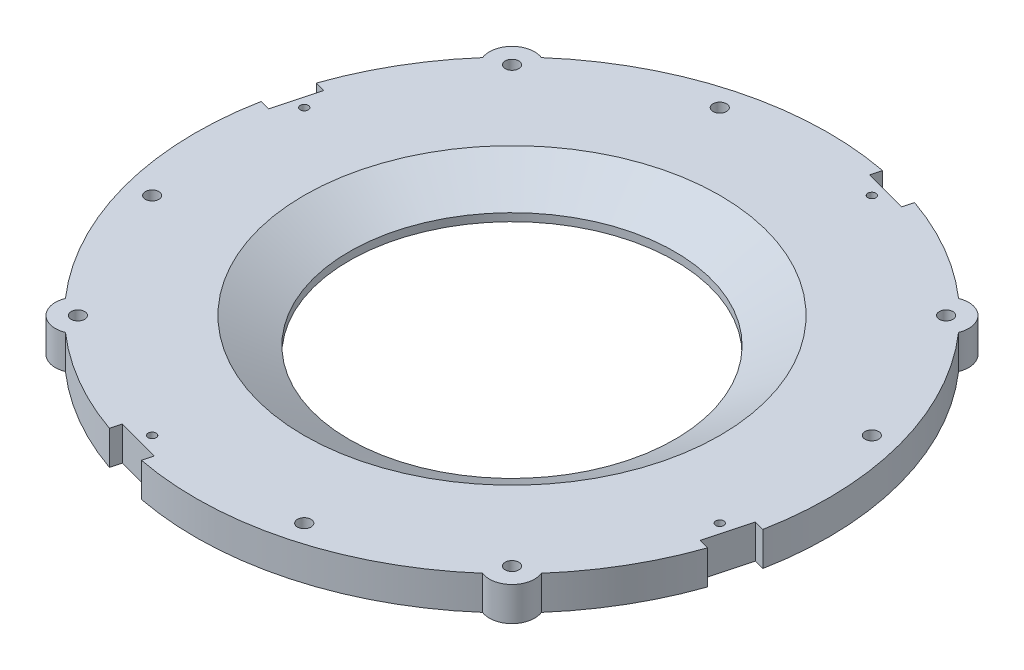
from build123d import *

# Parameters (mm, degrees)
SKETCH1_R           = 1.905
BOSS_EXTRUDE1_DEPTH = 9.525
SKETCH2_R           = 45.72
CUT_EXTRUDE1_DEPTH  = 12.7
SKETCH10_R          = 0.6985
CUT_EXTRUDE5_DEPTH  = 3.175
CIRPATTERN5_COUNT   = 4
CHAMFER1_SIZE       = 12.7
CHAMFER1_SIZE2      = 7.332348419
SKETCH4_R           = 1.905
CUT_EXTRUDE6_DEPTH  = 10.5250001
CIRPATTERN6_COUNT   = 4
SKETCH13_R          = 1.1303
CUT_EXTRUDE7_DEPTH  = 10.5250001
CIRPATTERN7_COUNT   = 4
SKETCH14_W          = 11.95230377
SKETCH14_H          = 12.7
CUT_EXTRUDE8_DEPTH  = 3.175
CIRPATTERN8_COUNT   = 4


with BuildPart() as part:
    # Sketch1 → Boss-Extrude1 (new body)
    with BuildSketch(Plane(origin=(0, 0, 0), x_dir=(1, 0, 0), z_dir=(0, 1, 0))):
        with BuildLine():
            ThreePointArc((-66.860826677, 58.590441679), (-88.9, 0), (-66.860826677, -58.590441679))
            ThreePointArc((-66.860826677, -58.590441679), (-65.466067123, -65.466067123), (-58.590441679, -66.860826677))
            ThreePointArc((-58.590441679, -66.860826677), (0, -88.9), (58.590441679, -66.860826677))
            ThreePointArc((58.590441679, -66.860826677), (65.466067123, -65.466067123), (66.860826677, -58.590441679))
            ThreePointArc((66.860826677, -58.590441679), (88.9, 0), (66.860826677, 58.590441679))
            ThreePointArc((66.860826677, 58.590441679), (65.466067123, 65.466067123), (58.590441679, 66.860826677))
            ThreePointArc((58.590441679, 66.860826677), (0, 88.9), (-58.590441679, 66.860826677))
            ThreePointArc((-58.590441679, 66.860826677), (-65.466067123, 65.466067123), (-66.860826677, 58.590441679))
        make_face()
        with Locations((-60.975939062, 60.975939062)):
            Circle(SKETCH1_R, mode=Mode.SUBTRACT)
        with Locations((60.975939062, 60.975939062)):
            Circle(SKETCH1_R, mode=Mode.SUBTRACT)
        with Locations((60.975939062, -60.975939062)):
            Circle(SKETCH1_R, mode=Mode.SUBTRACT)
        with Locations((-60.975939062, -60.975939062)):
            Circle(SKETCH1_R, mode=Mode.SUBTRACT)
    extrude(amount=BOSS_EXTRUDE1_DEPTH)

    # Sketch2 → Cut-Extrude1 (cut)
    with BuildSketch(Plane(origin=(0, 9.525, 0), x_dir=(1, 0, 0), z_dir=(0, 1, 0))):
        Circle(SKETCH2_R)
    extrude(amount=-CUT_EXTRUDE1_DEPTH, mode=Mode.SUBTRACT)

    # Sketch10 → Cut-Extrude5 (cut)
    with BuildSketch(Plane(origin=(-62.861792847, 0, -62.861792847), x_dir=(0, -1, 0), z_dir=(-0.707106781, 0, -0.707106781))):
        with Locations((-4.826, 0)):
            Circle(SKETCH10_R)
    cut_extrude5 = extrude(amount=-CUT_EXTRUDE5_DEPTH, mode=Mode.SUBTRACT)

    # CirPattern5: Cut-Extrude5 ×4 about axis
    cirpattern5_axis = Axis((0, 0, 0), (0, 1, 0))
    for i in range(1, CIRPATTERN5_COUNT):
        add(cut_extrude5.rotate(cirpattern5_axis, i * 360 / CIRPATTERN5_COUNT), mode=Mode.SUBTRACT)

    # Chamfer1
    chamfer1_edges = [part.edges().sort_by_distance(p)[0] for p in [
        (-45.72, 9.525, 0),
    ]]
    chamfer1_side = [part.faces().sort_by_distance(p)[0] for p in [
        (0, 9.525, -86.385528286),
    ]]
    chamfer(chamfer1_edges, length=CHAMFER1_SIZE, length2=CHAMFER1_SIZE2, reference=chamfer1_side[0])

    # Sketch4 → Cut-Extrude6 (cut, through all)
    with BuildSketch(Plane(origin=(0, 9.525, 0), x_dir=(1, 0, 0), z_dir=(0, 1, 0))):
        with Locations((-21.365512173, 79.73717696)):
            Circle(SKETCH4_R)
    cut_extrude6 = extrude(amount=-CUT_EXTRUDE6_DEPTH, mode=Mode.SUBTRACT)

    # CirPattern6: Cut-Extrude6 ×4 about axis
    cirpattern6_axis = Axis((0, 0, 0), (0, 1, 0))
    for i in range(1, CIRPATTERN6_COUNT):
        add(cut_extrude6.rotate(cirpattern6_axis, i * 360 / CIRPATTERN6_COUNT), mode=Mode.SUBTRACT)

    # Sketch13 → Cut-Extrude7 (cut, through all)
    with BuildSketch(Plane(origin=(0, 9.525, 0), x_dir=(1, 0, 0), z_dir=(0, 1, 0))):
        with Locations((21.365512173, 79.73717696)):
            Circle(SKETCH13_R)
    cut_extrude7 = extrude(amount=-CUT_EXTRUDE7_DEPTH, mode=Mode.SUBTRACT)

    # CirPattern7: Cut-Extrude7 ×4 about axis
    cirpattern7_axis = Axis((0, 0, 0), (0, 1, 0))
    for i in range(1, CIRPATTERN7_COUNT):
        add(cut_extrude7.rotate(cirpattern7_axis, i * 360 / CIRPATTERN7_COUNT), mode=Mode.SUBTRACT)

    # Sketch14 → Cut-Extrude8 (cut)
    with BuildSketch(Plane(origin=(23.00901311, 0, -85.870805957), x_dir=(0, -1, 0), z_dir=(0.258819045, 0, -0.965925826))):
        with Locations((-4.621692603, 0)):
            Rectangle(SKETCH14_W, SKETCH14_H)
    cut_extrude8 = extrude(amount=-CUT_EXTRUDE8_DEPTH, mode=Mode.SUBTRACT)

    # CirPattern8: Cut-Extrude8 ×4 about axis
    cirpattern8_axis = Axis((0, 0, 0), (0, 1, 0))
    for i in range(1, CIRPATTERN8_COUNT):
        add(cut_extrude8.rotate(cirpattern8_axis, i * 360 / CIRPATTERN8_COUNT), mode=Mode.SUBTRACT)


solid = part.part
